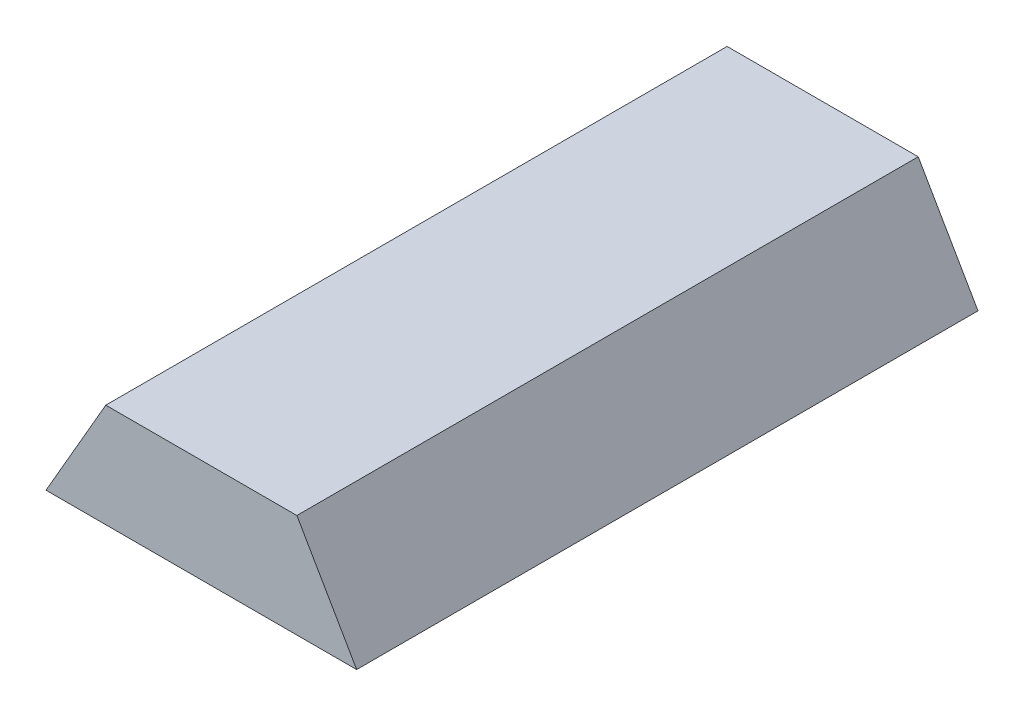
from build123d import *

# Parameters (mm, degrees)
BOSS_EXTRUDE1_DEPTH = 5


with BuildPart() as part:
    # Sketch1 → Boss-Extrude1 (new body)
    with BuildSketch(Plane.XY):
        Polygon((-1.246893784, -0.85418239), (1.253106216, -0.85418239), (0.771980992, -0.020849056), (-0.765768559, -0.020849056), align=None)
    extrude(amount=BOSS_EXTRUDE1_DEPTH)


solid = part.part
